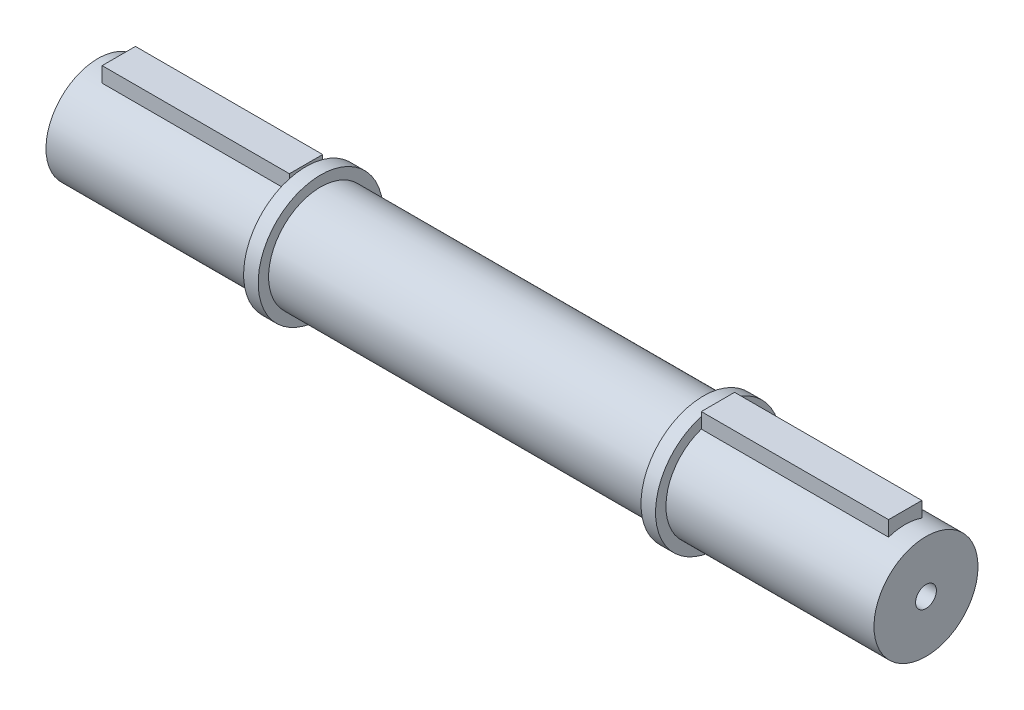
from build123d import *

# Parameters (mm, degrees)
CROQUIS1_R              = 12.5
SALIENTE_EXTRUIR1_DEPTH = 99.5
CROQUIS2_R              = 15
SALIENTE_EXTRUIR2_DEPTH = 3.5
CROQUIS4_W              = 8
CROQUIS4_H              = 3.657280718
SALIENTE_EXTRUIR3_DEPTH = 45
SALIENTE_EXTRUIR4_START = 99
CROQUIS4_2_W            = 8
CROQUIS4_2_H            = 3.657280718
SALIENTE_EXTRUIR4_DEPTH = 45
SALIENTE_EXTRUIR5_START = -92
CROQUIS2_2_R            = 15
SALIENTE_EXTRUIR5_DEPTH = 3.5
TALADRO_ROSCADO_M61_D   = 5


with BuildPart() as part:
    # Croquis1 → Saliente-Extruir1 (new body, symmetric)
    with BuildSketch(Plane(origin=(0, 0, 0), x_dir=(0, 0, -1), z_dir=(1, 0, 0))):
        Circle(CROQUIS1_R)
    extrude(amount=SALIENTE_EXTRUIR1_DEPTH, both=True)

    # Croquis2 → Saliente-Extruir2 (add)
    with BuildSketch(Plane(origin=(46, 0, 0), x_dir=(0, 0, -1), z_dir=(1, 0, 0))):
        Circle(CROQUIS2_R)
    extrude(amount=SALIENTE_EXTRUIR2_DEPTH)

    # Croquis4 → Saliente-Extruir3 (add)
    with BuildSketch(Plane.ZY.offset(-49.5)):
        with Locations((0, 13.671359641)):
            Rectangle(CROQUIS4_W, CROQUIS4_H)
    extrude(amount=-SALIENTE_EXTRUIR3_DEPTH)

    # Croquis4_2 → Saliente-Extruir4 (add)
    with BuildSketch(Plane.ZY.offset(-49.5).offset(SALIENTE_EXTRUIR4_START)):
        with Locations((0, 13.671359641)):
            Rectangle(CROQUIS4_2_W, CROQUIS4_2_H)
    extrude(amount=SALIENTE_EXTRUIR4_DEPTH)

    # Croquis2_2 → Saliente-Extruir5 (add)
    with BuildSketch(Plane(origin=(46, 0, 0), x_dir=(0, 0, -1), z_dir=(1, 0, 0)).offset(SALIENTE_EXTRUIR5_START)):
        Circle(CROQUIS2_2_R)
    extrude(amount=-SALIENTE_EXTRUIR5_DEPTH)

    # Taladro roscado M61 (through all)
    with Locations(Plane(origin=(99.5, 0, 0), x_dir=(0, 0, -1), z_dir=(1, 0, 0))):
        with Locations((0, 0)):
            Hole(TALADRO_ROSCADO_M61_D / 2)


solid = part.part
